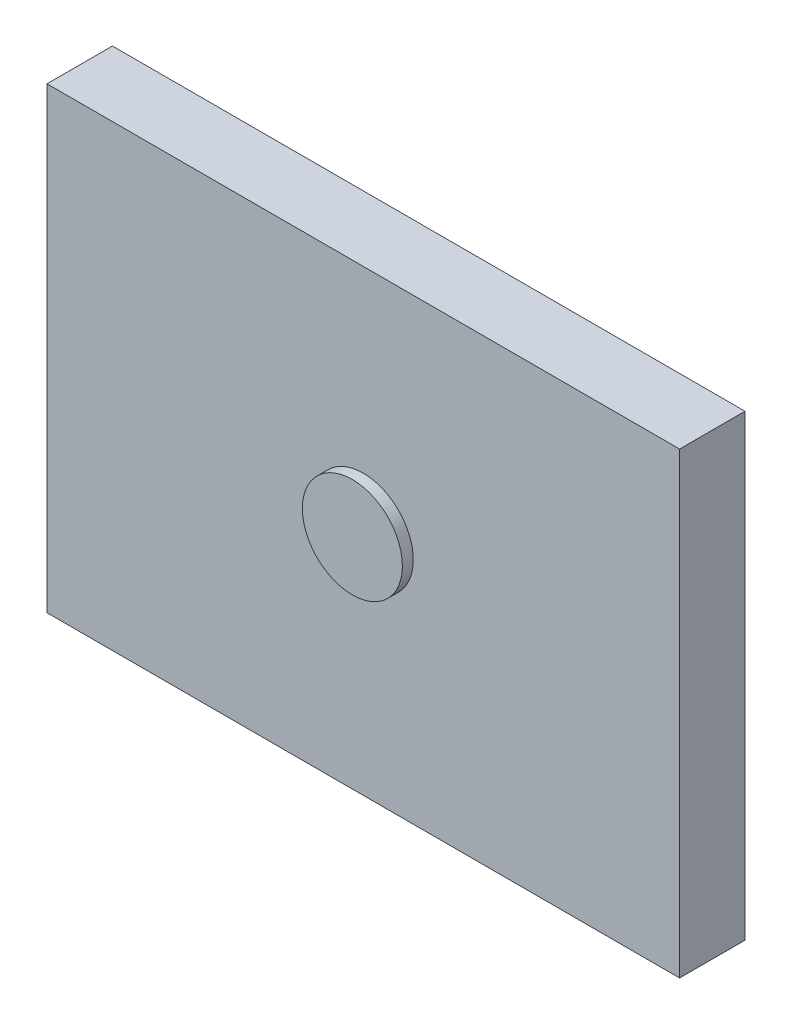
from build123d import *

# Parameters (mm, degrees)
SKETCH_1_W      = 290
SKETCH_1_H      = 210
EXTRUDE_1_DEPTH = 30
SKETCH_2_R      = 22.920324178
EXTRUDE_2_DEPTH = 5


with BuildPart() as part:
    # 草图1 → 凸台-拉伸1 (new body)
    with BuildSketch(Plane.XY):
        Rectangle(SKETCH_1_W, SKETCH_1_H)
    extrude(amount=EXTRUDE_1_DEPTH)

    # 草图2 → 凸台-拉伸2 (add)
    with BuildSketch(Plane.XY.offset(30)):
        Circle(SKETCH_2_R)
    extrude(amount=EXTRUDE_2_DEPTH)


solid = part.part
